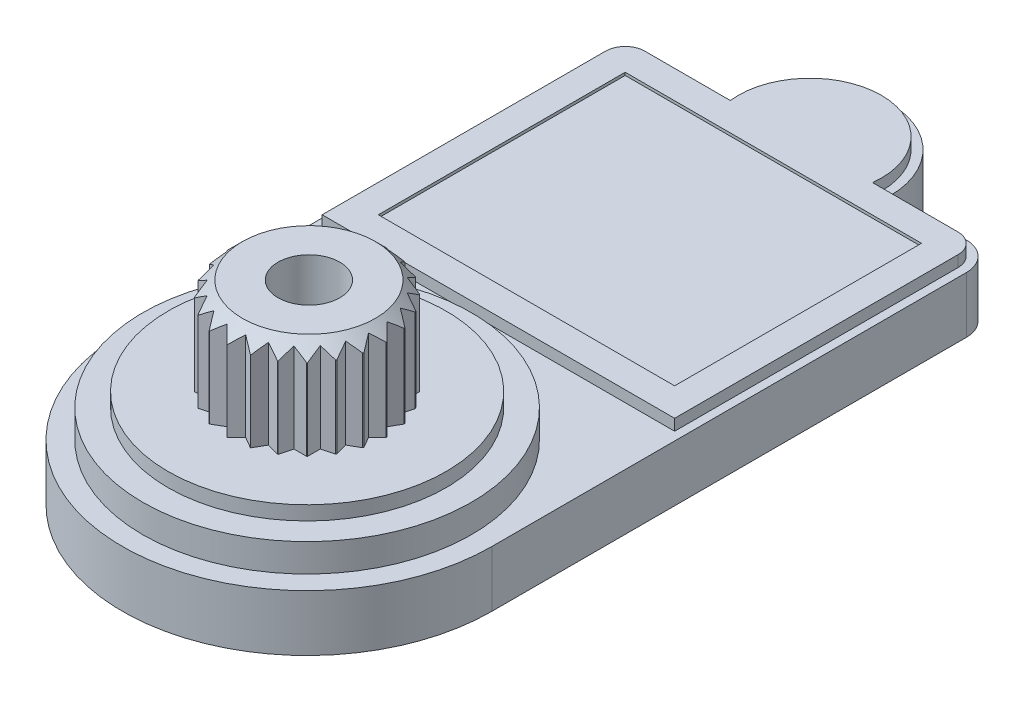
from build123d import *

# Parameters (mm, degrees)
SKETCH1_R           = 6.575
SKETCH1_R_2         = 1
BOSS_EXTRUDE1_DEPTH = 2
SKETCH2_R           = 5.85
BOSS_EXTRUDE2_DEPTH = 1
SKETCH3_R           = 4.95
BOSS_EXTRUDE3_DEPTH = 0.5
BOSS_EXTRUDE4_DEPTH = 3.4
SKETCH6_R           = 1.1
CUT_EXTRUDE1_DEPTH  = 4
BOSS_EXTRUDE5_DEPTH = 0.4
SKETCH8_W           = 10.55
SKETCH8_H           = 8.790176683
CUT_EXTRUDE2_DEPTH  = 0.1


with BuildPart() as part:
    # Sketch1 → Boss-Extrude1 (new body)
    with BuildSketch(Plane(origin=(0, 0, 0), x_dir=(1, 0, 0), z_dir=(0, 1, 0))):
        with Locations((0, -7.9)):
            Circle(SKETCH1_R)
        with BuildLine():
            Line((-2.85, 10), (-5.575, 10))
            ThreePointArc((-5.575, 10), (-4.867893219, 9.707106781), (-4.575, 9))
            ThreePointArc((-4.575, 9), (-5.574999999, 8), (-6.575, 8.999999999))
            Line((-6.575, 8.999999999), (-6.575, -7.9))
            ThreePointArc((-6.575, -7.9), (0, -1.325), (6.575, -7.9))
            Line((6.575, -7.9), (6.575, 9))
            ThreePointArc((6.575, 9), (4.867893224, 8.292893214), (5.574999986, 10))
            Line((5.574999986, 10), (2.85, 10))
            ThreePointArc((2.85, 10), (0, 7.15), (-2.85, 10))
        make_face()
        with Locations((-5.575, 9)):
            Circle(SKETCH1_R_2)
        with BuildLine():
            ThreePointArc((2.85, 10), (0, 12.85), (-2.85, 10))
            Line((-2.85, 10), (2.85, 10))
        make_face()
        with BuildLine():
            Line((2.85, 10), (-2.85, 10))
            ThreePointArc((-2.85, 10), (0, 7.15), (2.85, 10))
        make_face()
        with Locations((5.575, 9)):
            Circle(SKETCH1_R_2)
    extrude(amount=BOSS_EXTRUDE1_DEPTH)

    # Sketch2 → Boss-Extrude2 (add)
    with BuildSketch(Plane(origin=(0, 2, 0), x_dir=(-1, 0, 0), z_dir=(0, 1, 0))):
        with Locations((0, 7.9)):
            Circle(SKETCH2_R)
    extrude(amount=BOSS_EXTRUDE2_DEPTH)

    # Sketch3 → Boss-Extrude3 (add)
    with BuildSketch(Plane(origin=(0, 3, 0), x_dir=(-1, 0, 0), z_dir=(0, 1, 0))):
        with Locations((0, 7.9)):
            Circle(SKETCH3_R)
    extrude(amount=BOSS_EXTRUDE3_DEPTH)

    # Sketch4 → Boss-Extrude4 (add)
    with BuildSketch(Plane(origin=(0, 3.5, 0), x_dir=(-1, 0, 0), z_dir=(0, 1, 0))):
        Polygon((2.736417755, 7.190894071), (2.518440958, 7.568440958), (2.831329546, 7.881329546), (2.828587818, 7.921412182), (2.518440958, 8.231559042), (2.741390732, 8.617719379), (2.729517437, 8.651127629), (2.346813369, 8.872081926), (2.463209043, 9.306476495), (2.445926072, 9.330960886), (2.015254326, 9.446359032), (2.015254326, 9.900296057), (1.996868143, 9.915254326), (1.546359032, 9.915254326), (1.427678707, 10.35817533), (1.412422166, 10.36480218), (0.972081926, 10.246813369), (0.740314632, 10.648246096), (0.731654815, 10.64943636), (0.331559042, 10.418440958), (0, 10.75), (-0.331559042, 10.418440958), (-0.731654815, 10.64943636), (-0.740314632, 10.648246096), (-0.972081926, 10.246813369), (-1.412422166, 10.36480218), (-1.427678707, 10.35817533), (-1.546359032, 9.915254326), (-1.996868143, 9.915254326), (-2.015254326, 9.900296057), (-2.015254326, 9.446359032), (-2.445926072, 9.330960886), (-2.463209043, 9.306476495), (-2.346813369, 8.872081926), (-2.729517437, 8.651127629), (-2.741390732, 8.617719379), (-2.518440958, 8.231559042), (-2.828587818, 7.921412182), (-2.831329546, 7.881329546), (-2.518440958, 7.568440958), (-2.736417755, 7.190894071), (-2.727435802, 7.147670539), (-2.346813369, 6.927918074), (-2.459115706, 6.508800044), (-2.437318125, 6.466732622), (-2.015254326, 6.353640968), (-2.015254326, 5.921202275), (-1.981206238, 5.884745674), (-1.546359032, 5.884745674), (-1.434668452, 5.467910755), (-1.390523426, 5.441065569), (-0.972081926, 5.553186631), (-0.756489757, 5.179770042), (-0.705710775, 5.165542438), (-0.331559042, 5.381559042), (-0.026545054, 5.076545054), (0.026545054, 5.076545054), (0.331559042, 5.381559042), (0.705710775, 5.165542438), (0.756489757, 5.179770042), (0.972081926, 5.553186631), (1.390523426, 5.441065569), (1.434668452, 5.467910755), (1.546359032, 5.884745674), (1.981206238, 5.884745674), (2.015254326, 5.921202275), (2.015254326, 6.353640968), (2.437318125, 6.466732622), (2.459115706, 6.508800044), (2.346813369, 6.927918074), (2.727435802, 7.147670539), align=None)
    extrude(amount=BOSS_EXTRUDE4_DEPTH)

    # Sketch5 → Cut-Revolve1 (revolve, cut)
    with BuildSketch(Plane(origin=(0, 0, 0), x_dir=(0, 0, -1), z_dir=(1, 0, 0))):
        Polygon((-5.867221225, 7.3), (-4.517199782, 7.3), (-4.517199782, 5.949978558), align=None)
    revolve(axis=Axis((0, 8.077813164, 7.836091173), (0, -1, 0)), mode=Mode.SUBTRACT)

    # Sketch6 → Cut-Extrude1 (cut)
    with BuildSketch(Plane(origin=(0, 6.9, 0), x_dir=(-1, 0, 0), z_dir=(0, 1, 0))):
        with Locations((0, 7.836091173)):
            Circle(SKETCH6_R)
    extrude(amount=-CUT_EXTRUDE1_DEPTH, mode=Mode.SUBTRACT)

    # Sketch7 → Boss-Extrude5 (add)
    with BuildSketch(Plane(origin=(0, 2, 0), x_dir=(-1, 0, 0), z_dir=(0, 1, 0))):
        with BuildLine():
            Line((2.532291452, -9.7), (5.575, -9.7))
            ThreePointArc((5.575, -9.7), (6.069974747, -9.494974747), (6.275, -9))
            Line((6.275, -9), (6.275, 1.090176683))
            Line((6.275, 1.090176683), (-6.275, 1.090176683))
            Line((-6.275, 1.090176683), (-6.275, -1.654552581))
            Line((-6.275, -1.654552581), (-6.275, -9))
            ThreePointArc((-6.275, -9), (-6.069974747, -9.494974747), (-5.575, -9.7))
            Line((-5.575, -9.7), (-2.532291452, -9.7))
            ThreePointArc((-2.532291452, -9.7), (0, -12.55), (2.532291452, -9.7))
        make_face()
    extrude(amount=BOSS_EXTRUDE5_DEPTH)

    # Sketch8 → Cut-Extrude2 (cut)
    with BuildSketch(Plane(origin=(0, 2.4, 0), x_dir=(-1, 0, 0), z_dir=(0, 1, 0))):
        with Locations((0, -4.304911659)):
            Rectangle(SKETCH8_W, SKETCH8_H)
    extrude(amount=-CUT_EXTRUDE2_DEPTH, mode=Mode.SUBTRACT)


solid = part.part
